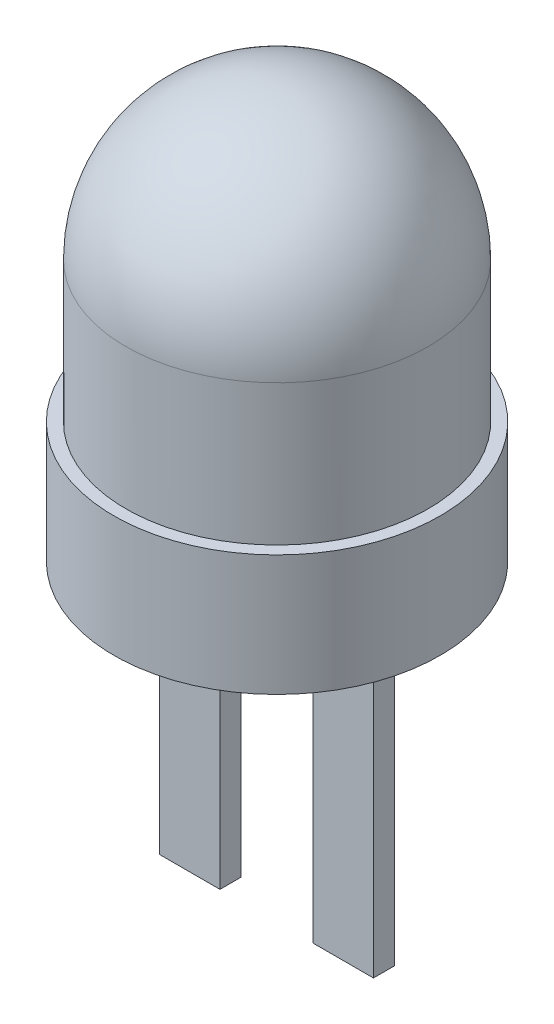
from build123d import *

# Parameters (mm, degrees)
SKETCH2_W                = 1
SKETCH2_H                = 0.35
BOSS_EXTRUDE1_DEPTH      = 5
BOSS_EXTRUDE1_DEPTH_BACK = 5


with BuildPart() as part:
    # Sketch1 → Revolve1 (revolve)
    with BuildSketch(Plane.XY):
        with BuildLine():
            Line((0, 0), (0, 6.825))
            ThreePointArc((0, 6.825), (1.767766953, 6.092766953), (2.5, 4.325))
            Line((2.5, 4.325), (2.5, 2))
            Line((2.5, 2), (2.7, 2))
            Line((2.7, 2), (2.7, 0))
            Line((2.7, 0), (0, 0))
        make_face()
    revolve(axis=Axis((0, 0, 0), (0, 1, 0)))

    # Sketch2 → Boss-Extrude1 (add, two sides)
    with BuildSketch(Plane.XZ) as boss_extrude1_sk:
        with Locations((1.27, 0)):
            Rectangle(SKETCH2_W, SKETCH2_H)
        with Locations((-1.27, 0)):
            Rectangle(SKETCH2_W, SKETCH2_H)
    extrude(amount=BOSS_EXTRUDE1_DEPTH)
    extrude(boss_extrude1_sk.sketch, amount=-BOSS_EXTRUDE1_DEPTH_BACK)


solid = part.part
